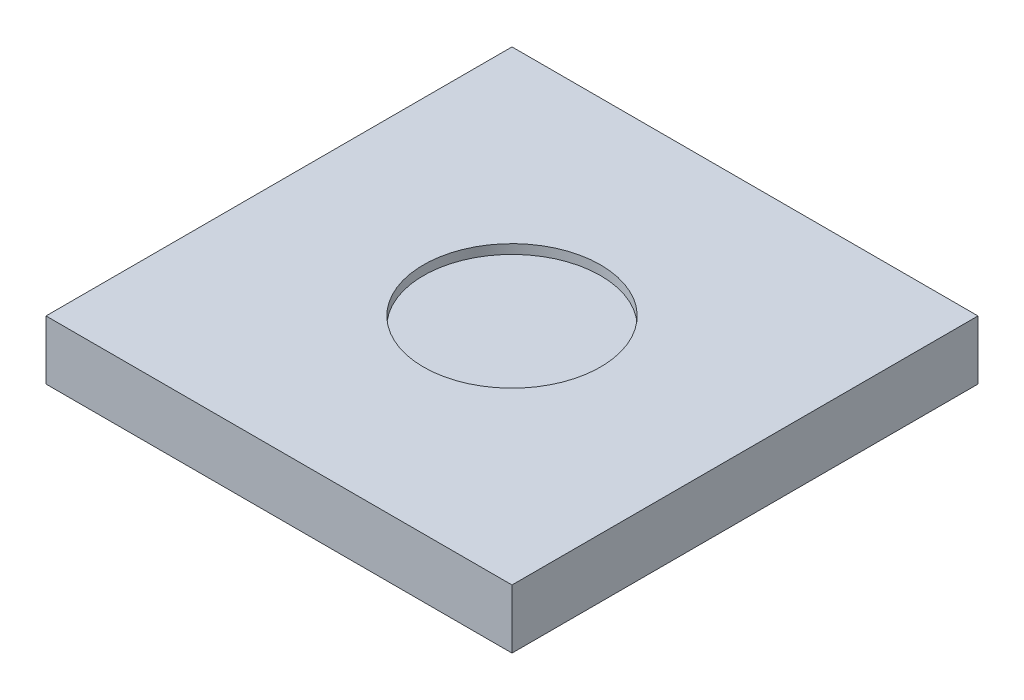
from build123d import *

# Parameters (mm, degrees)
SKETCH1_W           = 150
SKETCH1_H           = 150
BOSS_EXTRUDE1_DEPTH = 19
SKETCH2_R           = 28.5
CUT_EXTRUDE1_DEPTH  = 3


with BuildPart() as part:
    # Sketch1 → Boss-Extrude1 (new body)
    with BuildSketch(Plane(origin=(0, 0, 0), x_dir=(1, 0, 0), z_dir=(0, 1, 0))):
        with Locations((75, 75)):
            Rectangle(SKETCH1_W, SKETCH1_H)
    extrude(amount=BOSS_EXTRUDE1_DEPTH)

    # Sketch2 → Cut-Extrude1 (cut)
    with BuildSketch(Plane(origin=(0, 19, 0), x_dir=(1, 0, 0), z_dir=(0, 1, 0))):
        with Locations((75, 75)):
            Circle(SKETCH2_R)
    extrude(amount=-CUT_EXTRUDE1_DEPTH, mode=Mode.SUBTRACT)


solid = part.part
